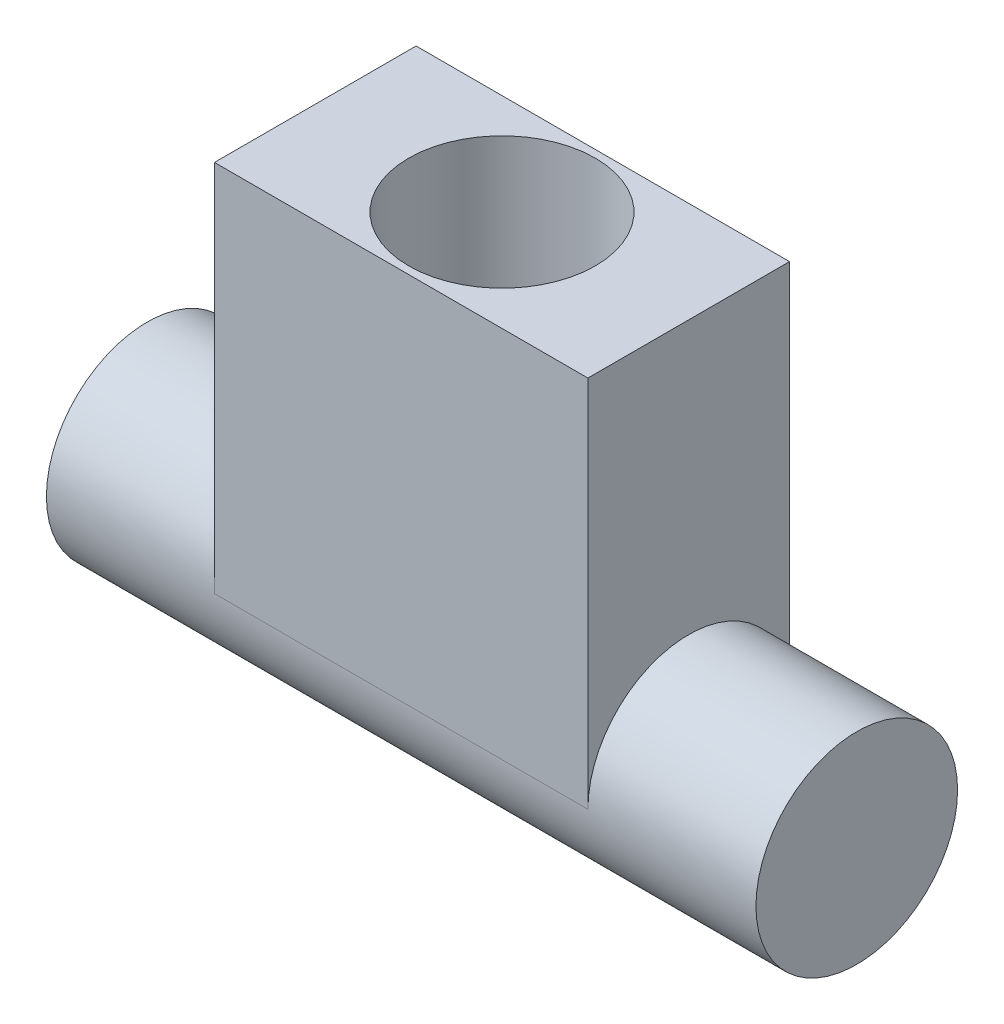
from build123d import *

# Parameters (mm, degrees)
SKETCH1_R           = 2.7
BOSS_EXTRUDE1_DEPTH = 19
SKETCH2_W           = 10
SKETCH2_H           = 5.4
BOSS_EXTRUDE2_DEPTH = 10
SKETCH3_R           = 2.5
CUT_EXTRUDE1_DEPTH  = 5


with BuildPart() as part:
    # Sketch1 → Boss-Extrude1 (new body)
    with BuildSketch(Plane(origin=(0, 0, 0), x_dir=(0, 0, -1), z_dir=(1, 0, 0))):
        Circle(SKETCH1_R)
    extrude(amount=BOSS_EXTRUDE1_DEPTH)

    # Sketch2 → Boss-Extrude2 (add)
    with BuildSketch(Plane(origin=(0, 0, 0), x_dir=(1, 0, 0), z_dir=(0, 1, 0))):
        with Locations((9.5, 0)):
            Rectangle(SKETCH2_W, SKETCH2_H)
    extrude(amount=BOSS_EXTRUDE2_DEPTH)

    # Sketch3 → Cut-Extrude1 (cut)
    with BuildSketch(Plane(origin=(0, 10, 0), x_dir=(1, 0, 0), z_dir=(0, 1, 0))):
        with Locations((9.5, 0)):
            Circle(SKETCH3_R)
    extrude(amount=-CUT_EXTRUDE1_DEPTH, mode=Mode.SUBTRACT)


solid = part.part
